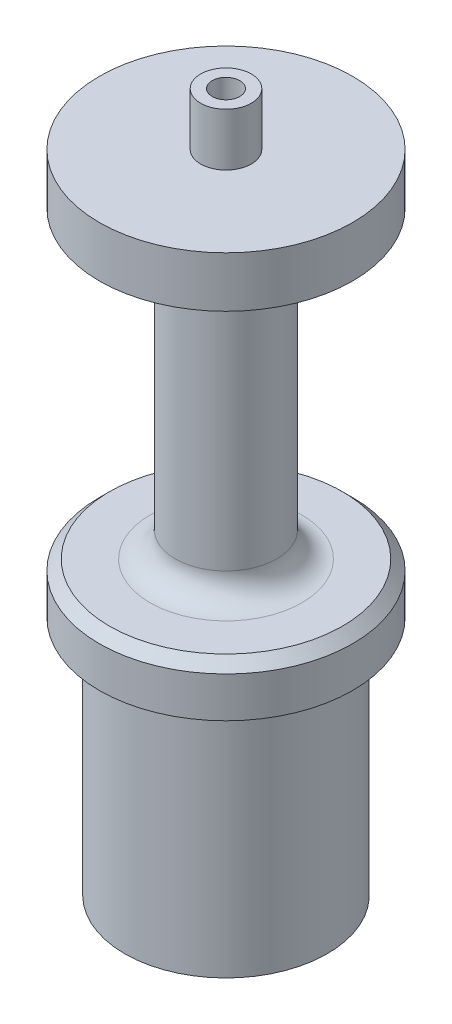
from build123d import *

# Parameters (mm, degrees)
SKETCH1_R             = 12.7
BOSS_EXTRUDE1_DEPTH   = 30.1625
SKETCH4_R             = 15.875
BOSS_EXTRUDE2_DEPTH   = 50.8
CUT_EXTRUDE1_DEPTH    = 11.176
SKETCH3_R             = 6
CUT_EXTRUDE2_DEPTH    = 8
SKETCH5_R             = 3.175
BOSS_EXTRUDE3_DEPTH   = 6.604
F_8_32_TAPPED_HOLE1_D = 3.4544
CUT_EXTRUDE3_START    = -6.35
SKETCH9_R             = 15.875
SKETCH9_R_2           = 6.35
CUT_EXTRUDE3_DEPTH    = 38.1
FILLET1_R             = 3.175
CHAMFER1_SIZE         = 1.27


with BuildPart() as part:
    # Sketch1 → Boss-Extrude1 (new body)
    with BuildSketch(Plane(origin=(0, 0, 0), x_dir=(1, 0, 0), z_dir=(0, 1, 0))):
        Circle(SKETCH1_R)
    extrude(amount=BOSS_EXTRUDE1_DEPTH)

    # Sketch4 → Boss-Extrude2 (add)
    with BuildSketch(Plane(origin=(0, 30.1625, 0), x_dir=(1, 0, 0), z_dir=(0, 1, 0))):
        Circle(SKETCH4_R)
    extrude(amount=BOSS_EXTRUDE2_DEPTH)

    # Sketch2 → Cut-Extrude1 (cut)
    with BuildSketch(Plane.XZ):
        with BuildLine():
            Line((-7, 2.899494937), (-8.776962921, 1.122532015))
            ThreePointArc((-8.776962921, 1.122532015), (-9.241930906, 0), (-8.776962921, -1.122532015))
            Line((-8.776962921, -1.122532015), (-7, -2.899494937))
            Line((-7, -2.899494937), (-7, 2.899494937))
        make_face()
        Polygon((-2.899494937, 7), (-7, 2.899494937), (-7, -2.899494937), (-2.899494937, -7), (2.899494937, -7), (7, -2.899494937), (7, 2.899494937), (2.899494937, 7), align=None)
        with BuildLine():
            Line((-7, 5.4125), (-7, 2.899494937))
            Line((-7, 2.899494937), (-2.899494937, 7))
            Line((-2.899494937, 7), (-5.4125, 7))
            ThreePointArc((-5.4125, 7), (-6.535032015, 6.535032015), (-7, 5.4125))
        make_face()
        with BuildLine():
            Line((-1.122532015, 8.776962921), (-2.899494937, 7))
            Line((-2.899494937, 7), (2.899494937, 7))
            Line((2.899494937, 7), (1.122532015, 8.776962921))
            ThreePointArc((1.122532015, 8.776962921), (0, 9.241930906), (-1.122532015, 8.776962921))
        make_face()
        with BuildLine():
            Line((5.4125, 7), (2.899494937, 7))
            Line((2.899494937, 7), (7, 2.899494937))
            Line((7, 2.899494937), (7, 5.4125))
            ThreePointArc((7, 5.4125), (6.535032015, 6.535032015), (5.4125, 7))
        make_face()
        with BuildLine():
            Line((8.776962921, 1.122532015), (7, 2.899494937))
            Line((7, 2.899494937), (7, -2.899494937))
            Line((7, -2.899494937), (8.776962921, -1.122532015))
            ThreePointArc((8.776962921, -1.122532015), (9.241930906, 0), (8.776962921, 1.122532015))
        make_face()
        with BuildLine():
            Line((7, -2.899494937), (2.899494937, -7))
            Line((2.899494937, -7), (5.4125, -7))
            ThreePointArc((5.4125, -7), (6.535032015, -6.535032015), (7, -5.4125))
            Line((7, -5.4125), (7, -2.899494937))
        make_face()
        with BuildLine():
            Line((2.899494937, -7), (-2.899494937, -7))
            Line((-2.899494937, -7), (-1.122532015, -8.776962921))
            ThreePointArc((-1.122532015, -8.776962921), (0, -9.241930906), (1.122532015, -8.776962921))
            Line((1.122532015, -8.776962921), (2.899494937, -7))
        make_face()
        with BuildLine():
            Line((-2.899494937, -7), (-7, -2.899494937))
            Line((-7, -2.899494937), (-7, -5.4125))
            ThreePointArc((-7, -5.4125), (-6.535032015, -6.535032015), (-5.4125, -7))
            Line((-5.4125, -7), (-2.899494937, -7))
        make_face()
    extrude(amount=-CUT_EXTRUDE1_DEPTH, mode=Mode.SUBTRACT)

    # Sketch3 → Cut-Extrude2 (cut)
    with BuildSketch(Plane.XZ.offset(-11.176)):
        Circle(SKETCH3_R)
    extrude(amount=-CUT_EXTRUDE2_DEPTH, mode=Mode.SUBTRACT)

    # Sketch5 → Boss-Extrude3 (add)
    with BuildSketch(Plane(origin=(0, 80.9625, 0), x_dir=(1, 0, 0), z_dir=(0, 1, 0))):
        Circle(SKETCH5_R)
    extrude(amount=BOSS_EXTRUDE3_DEPTH)

    # #8-32 Tapped Hole1 (through all)
    with Locations(Plane(origin=(0, 87.5665, 0), x_dir=(1, 0, 0), z_dir=(0, 1, 0))):
        with Locations((0, 0)):
            Hole(F_8_32_TAPPED_HOLE1_D / 2)

    # Sketch9 → Cut-Extrude3 (cut)
    with BuildSketch(Plane(origin=(0, 80.9625, 0), x_dir=(1, 0, 0), z_dir=(0, 1, 0)).offset(CUT_EXTRUDE3_START)):
        Circle(SKETCH9_R)
        Circle(SKETCH9_R_2, mode=Mode.SUBTRACT)
    extrude(amount=-CUT_EXTRUDE3_DEPTH, mode=Mode.SUBTRACT)

    # Fillet1
    fillet1_edges = [part.edges().sort_by_distance(p)[0] for p in [
        (-6.35, 36.5125, 0),
        (-6.35, 74.6125, 0),
    ]]
    fillet(fillet1_edges, radius=FILLET1_R)

    # Chamfer1
    chamfer1_edges = [part.edges().sort_by_distance(p)[0] for p in [
        (-15.875, 36.5125, 0),
    ]]
    chamfer(chamfer1_edges, length=CHAMFER1_SIZE)


solid = part.part
